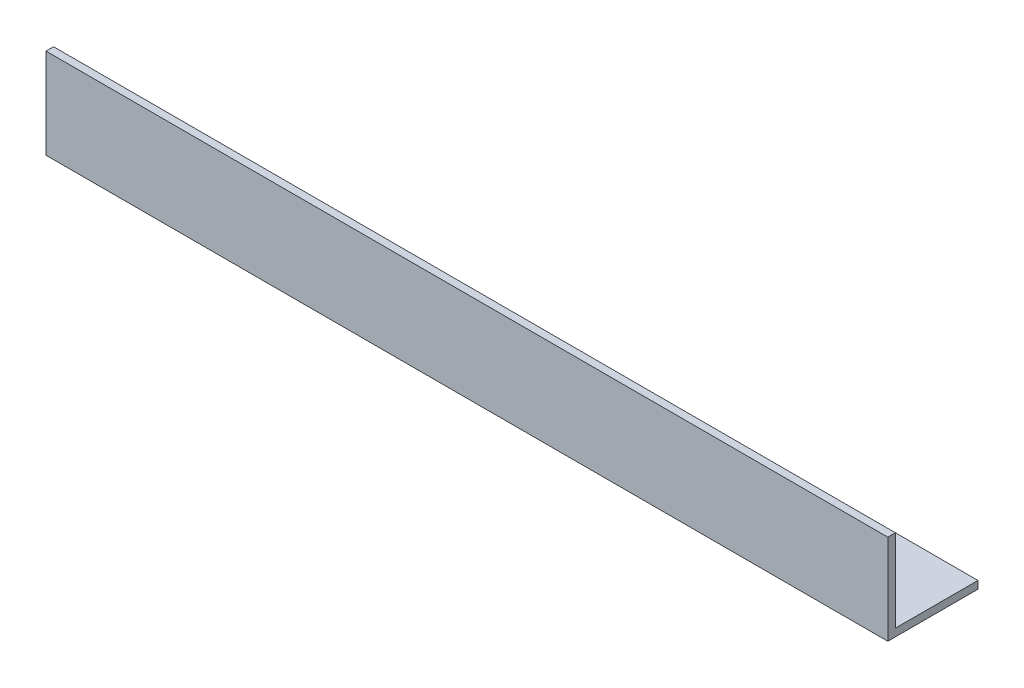
from build123d import *

# Parameters (mm, degrees)
BOSS_EXTRUDE1_DEPTH = 177.8


with BuildPart() as part:
    # Sketch1 → Boss-Extrude1 (new body)
    with BuildSketch(Plane(origin=(0, 0, 0), x_dir=(0, 0, -1), z_dir=(1, 0, 0))):
        Polygon((0, 0), (0, 19.05), (1.6002, 19.05), (1.6002, 1.6002), (19.05, 1.6002), (19.05, 0), align=None)
    extrude(amount=BOSS_EXTRUDE1_DEPTH)


solid = part.part
